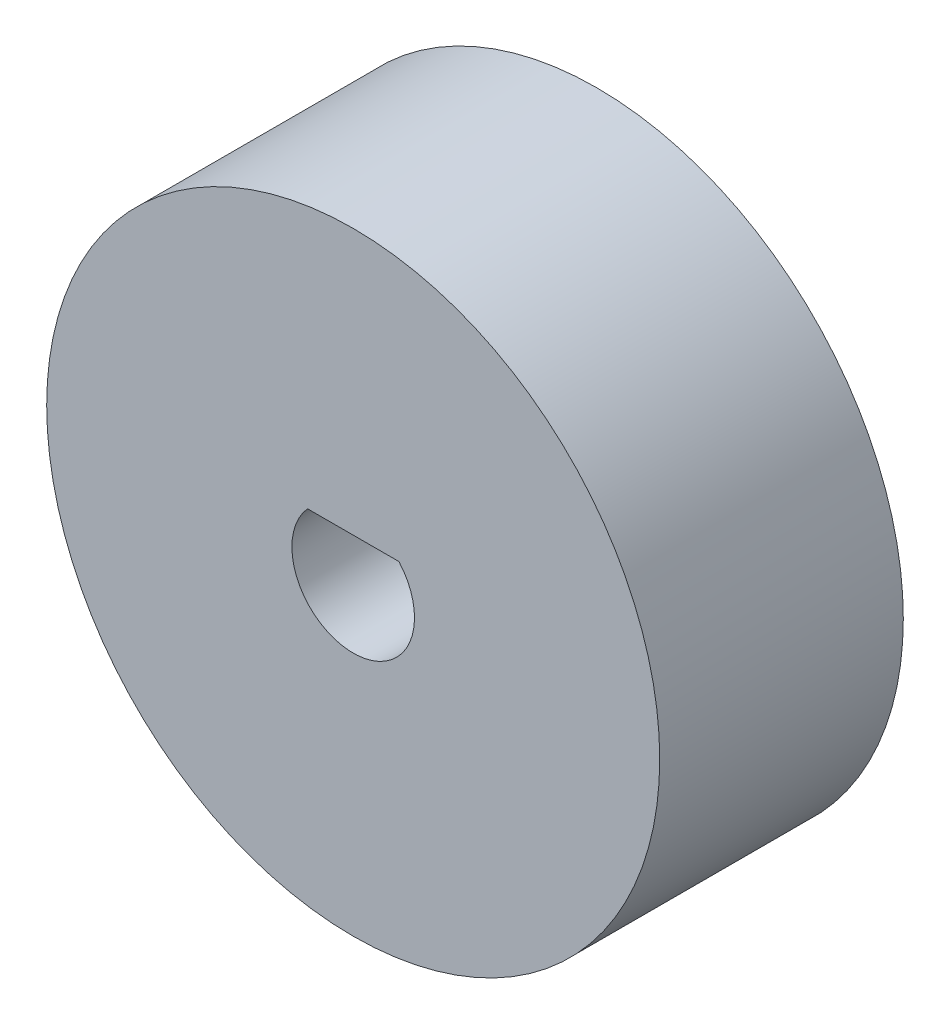
from build123d import *

# Parameters (mm, degrees)
SKETCH1_R                       = 7.5
SKETCH1_R_2                     = 2.5
BOSS_EXTRUDE2_DEPTH             = 2.98
BOSS_EXTRUDE3_REACH             = 13.017
SKETCH1_5_R                     = 2.5
BOSS_EXTRUDE3_DIRECTION_2_REACH = 13.017


with BuildPart() as part:
    # Sketch1 → Boss-Extrude2 (new, symmetric)
    with BuildSketch(Plane.XY):
        Circle(SKETCH1_R)
        Circle(SKETCH1_R_2, mode=Mode.SUBTRACT)
    extrude(amount=BOSS_EXTRUDE2_DEPTH, both=True)

    # Boss-Extrude3: up to this face of the body (flat: up to its plane)
    boss_extrude3_end = Plane(part.part.faces().sort_by_distance((-7.287867966, 0, 2.98))[0])
    # Sketch1_5 → Boss-Extrude3 (add, up to the picked face)
    with BuildSketch(Plane.XY, mode=Mode.PRIVATE) as boss_extrude3_sk1:
        Circle(SKETCH1_5_R)
        with BuildLine():
            ThreePointArc((1.118033989, 1), (0, -1.5), (-1.118033989, 1))
            Line((-1.118033989, 1), (1.118033989, 1))
        make_face(mode=Mode.SUBTRACT)
    boss_extrude3_tool1 = split(extrude(boss_extrude3_sk1.sketch, amount=BOSS_EXTRUDE3_REACH, mode=Mode.PRIVATE), bisect_by=boss_extrude3_end, keep=Keep.BOTH, mode=Mode.PRIVATE)
    add(boss_extrude3_tool1.solids().sort_by(Axis((-2.429289, 0, 0), (0, 0, 1)))[0])

    # Boss-Extrude3 direction 2: up to this face of the body (flat: up to its plane)
    boss_extrude3_direction_2_end = Plane(part.part.faces().sort_by_distance((-7.287867966, 0, -2.98))[0])
    # Sketch1_5 → Boss-Extrude3 direction 2 (add, up to the picked face)
    with BuildSketch(Plane.XY, mode=Mode.PRIVATE) as boss_extrude3_direction_2_sk1:
        Circle(SKETCH1_5_R)
        with BuildLine():
            ThreePointArc((1.118033989, 1), (0, -1.5), (-1.118033989, 1))
            Line((-1.118033989, 1), (1.118033989, 1))
        make_face(mode=Mode.SUBTRACT)
    boss_extrude3_direction_2_tool1 = split(extrude(boss_extrude3_direction_2_sk1.sketch, amount=-BOSS_EXTRUDE3_DIRECTION_2_REACH, mode=Mode.PRIVATE), bisect_by=boss_extrude3_direction_2_end, keep=Keep.BOTH, mode=Mode.PRIVATE)
    add(boss_extrude3_direction_2_tool1.solids().sort_by(Axis((-2.429289, 0, 0), (0, 0, -1)))[0])


solid = part.part
